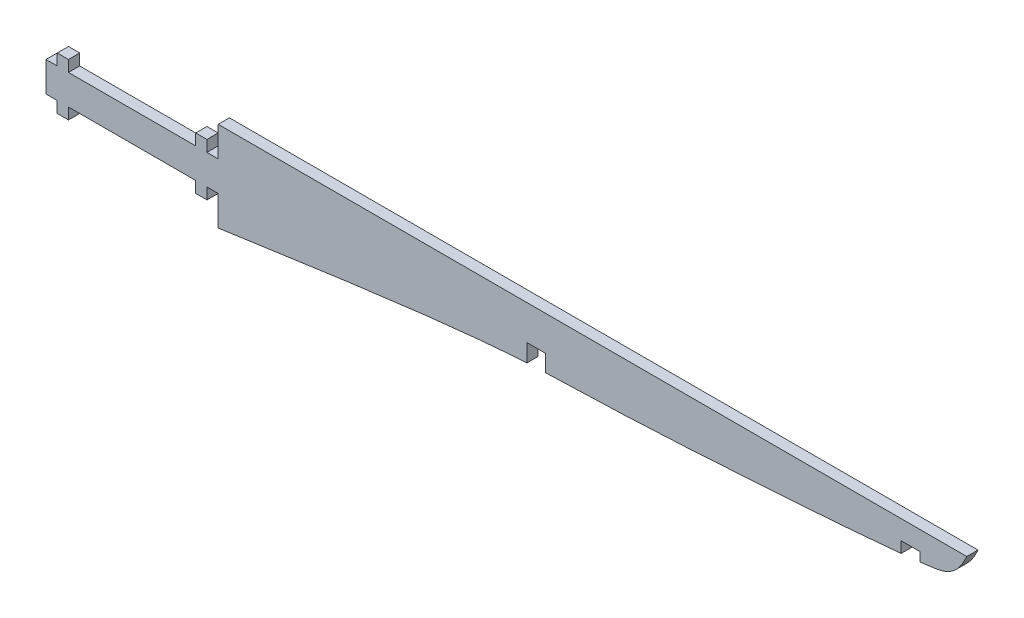
from build123d import *

# Parameters (mm, degrees)
SKETCH1_W           = 3
SKETCH1_H           = 3
SKETCH1_H_2         = 8
SKETCH1_W_2         = 34
BOSS_EXTRUDE1_DEPTH = 3
BOSS_EXTRUDE2_DEPTH = 3
SKETCH4_W           = 5
SKETCH4_H           = 11.505026735
SKETCH4_H_2         = 15.63867488
CUT_EXTRUDE1_DEPTH  = 4.0000001


with BuildPart() as part:
    # Sketch1 → Boss-Extrude1 (new body)
    with BuildSketch(Plane.XY):
        with Locations((-18.5, 5.5)):
            Rectangle(SKETCH1_W, SKETCH1_H)
        with Locations((-21.5, 0)):
            Rectangle(SKETCH1_W, SKETCH1_H_2)
        with Locations((-18.5, 0)):
            Rectangle(SKETCH1_W, SKETCH1_H_2)
        with Locations((-18.5, -5.5)):
            Rectangle(SKETCH1_W, SKETCH1_H)
        Rectangle(SKETCH1_W_2, SKETCH1_H_2)
        with Locations((21.5, 0)):
            Rectangle(SKETCH1_W, SKETCH1_H_2)
        with Locations((18.5, 0)):
            Rectangle(SKETCH1_W, SKETCH1_H_2)
        with Locations((18.5, 5.5)):
            Rectangle(SKETCH1_W, SKETCH1_H)
        with Locations((18.5, -5.5)):
            Rectangle(SKETCH1_W, SKETCH1_H)
    extrude(amount=BOSS_EXTRUDE1_DEPTH)

    # Sketch2 → Boss-Extrude2 (add)
    with BuildSketch(Plane.XY.offset(3)):
        with BuildLine():
            Line((23, -12), (23, 12))
            Line((23, 12), (223, 12))
            add(Edge.make_bspline(
                [(223, 12), (221.140597213, 7.892255131), (218.702083634, 6.19593369), (212.790204305, 3.931408425), (103.066716712, -3.738921761), (102.009324238, -0.499389529), (23, -12)],
                knots=[0, 0, 0, 0, 0.169852777, 0.23255249, 0.583169949, 1, 1, 1, 1], degree=3))
        make_face()
    extrude(amount=-BOSS_EXTRUDE2_DEPTH)

    # Sketch4 → Cut-Extrude1 (cut, through all)
    with BuildSketch(Plane.XY.offset(3)):
        with Locations((107.956458128, -3.008631932)):
            Rectangle(SKETCH4_W, SKETCH4_H)
        with Locations((207.956458128, -0.941807859)):
            Rectangle(SKETCH4_W, SKETCH4_H_2)
    extrude(amount=-CUT_EXTRUDE1_DEPTH, mode=Mode.SUBTRACT)


solid = part.part
